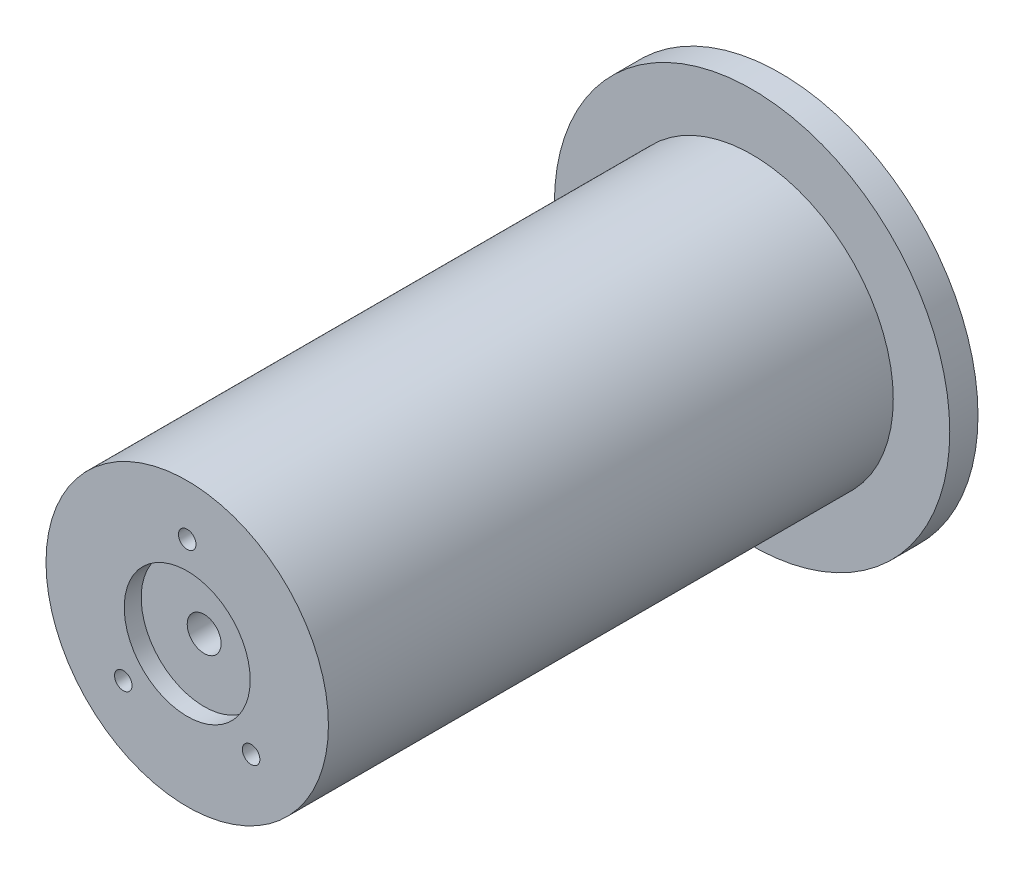
from build123d import *

# Parameters (mm, degrees)
SKETCH_1_R          = 25
EXTRUDE_1_DEPTH     = 100
SKETCH_2_R          = 35
EXTRUDE_2_DEPTH     = 5
SKETCH_4_R          = 9.8
CUT_EXTRUDE_1_DEPTH = 7
SKETCH_5_R          = 3
CUT_EXTRUDE_2_DEPTH = 106
SKETCH_6_R          = 1.5
CUT_EXTRUDE_3_DEPTH = 10
SKETCH_7_R          = 11.15
CUT_EXTRUDE_4_DEPTH = 3
SKETCH_8_R          = 1.55
CUT_EXTRUDE_5_DEPTH = 10


with BuildPart() as part:
    # Эскиз1 → Бобышка-Вытянуть1 (new body)
    with BuildSketch(Plane.XY):
        Circle(SKETCH_1_R)
    extrude(amount=EXTRUDE_1_DEPTH)

    # Эскиз2 → Бобышка-Вытянуть2 (add)
    with BuildSketch(Plane(origin=(0, 0, 0), x_dir=(-1, 0, 0), z_dir=(0, 0, -1))):
        Circle(SKETCH_2_R)
    extrude(amount=EXTRUDE_2_DEPTH)

    # Эскиз4 → Вырез-Вытянуть1 (cut)
    with BuildSketch(Plane(origin=(0, 0, -5), x_dir=(-1, 0, 0), z_dir=(0, 0, -1))):
        Circle(SKETCH_4_R)
    extrude(amount=-CUT_EXTRUDE_1_DEPTH, mode=Mode.SUBTRACT)

    # Эскиз5 → Вырез-Вытянуть2 (cut, through all)
    with BuildSketch(Plane(origin=(0, 0, -5), x_dir=(-1, 0, 0), z_dir=(0, 0, -1))):
        Circle(SKETCH_5_R)
    extrude(amount=-CUT_EXTRUDE_2_DEPTH, mode=Mode.SUBTRACT)

    # Эскиз6 → Вырез-Вытянуть3 (cut)
    with BuildSketch(Plane(origin=(0, 0, -5), x_dir=(-1, 0, 0), z_dir=(0, 0, -1))):
        with Locations((0, 13)):
            Circle(SKETCH_6_R)
        with Locations((11.258330249, -6.5)):
            Circle(SKETCH_6_R)
        with Locations((-11.258330249, -6.5)):
            Circle(SKETCH_6_R)
    extrude(amount=-CUT_EXTRUDE_3_DEPTH, mode=Mode.SUBTRACT)

    # Эскиз7 → Вырез-Вытянуть4 (cut)
    with BuildSketch(Plane.XY.offset(100)):
        Circle(SKETCH_7_R)
    extrude(amount=-CUT_EXTRUDE_4_DEPTH, mode=Mode.SUBTRACT)

    # Эскиз8 → Вырез-Вытянуть5 (cut)
    with BuildSketch(Plane.XY.offset(100)):
        with Locations((0, 16)):
            Circle(SKETCH_8_R)
        with Locations((-11.313708499, -11.313708499)):
            Circle(SKETCH_8_R)
        with Locations((11.313708499, -11.313708499)):
            Circle(SKETCH_8_R)
    extrude(amount=-CUT_EXTRUDE_5_DEPTH, mode=Mode.SUBTRACT)


solid = part.part
